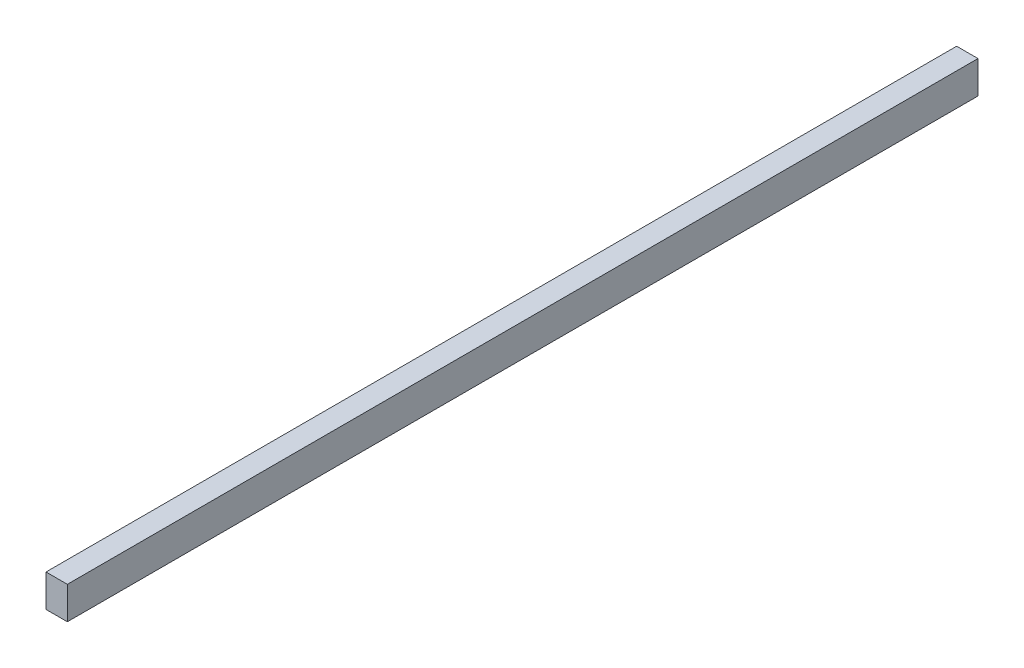
from build123d import *

# Parameters (mm, degrees)
SKETCH1_W           = 38.1
SKETCH1_H           = 57.94375
BOSS_EXTRUDE1_DEPTH = 1625.6


with BuildPart() as part:
    # Sketch1 → Boss-Extrude1 (new body)
    with BuildSketch(Plane.XY):
        with Locations((10.354897237, 6.011153832)):
            Rectangle(SKETCH1_W, SKETCH1_H)
    extrude(amount=BOSS_EXTRUDE1_DEPTH)


solid = part.part
